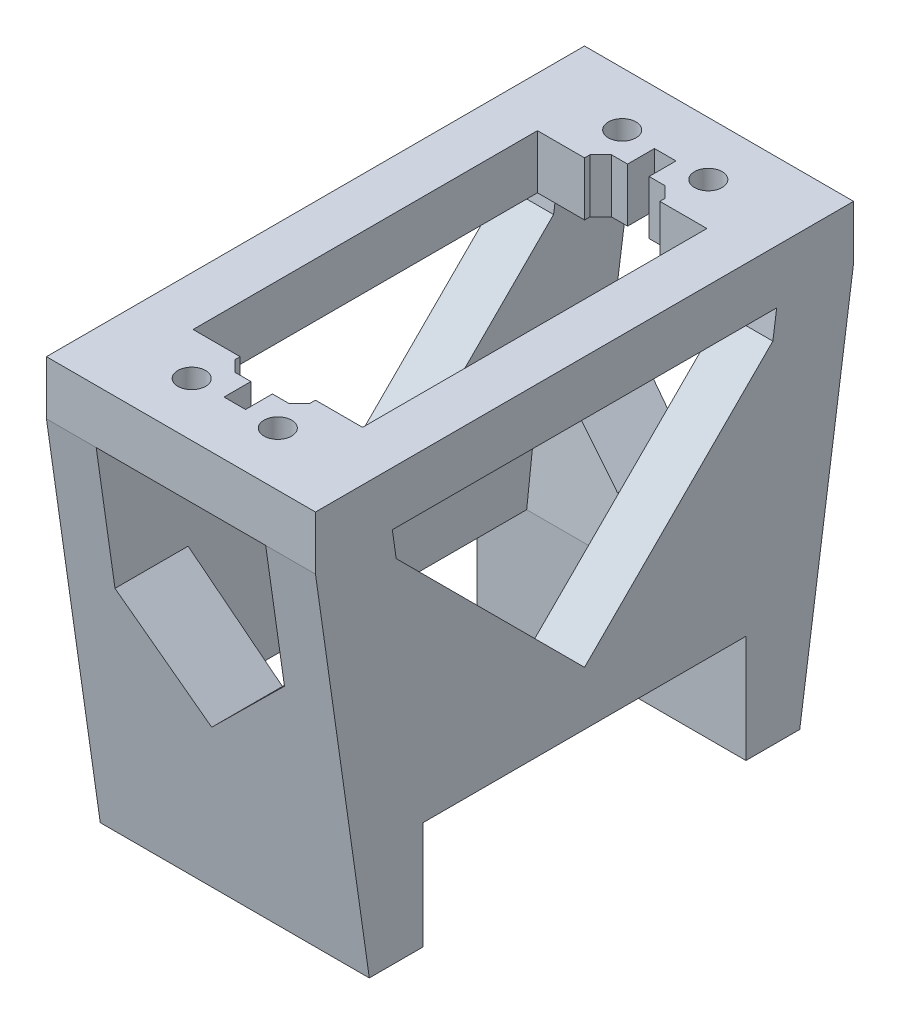
from build123d import *
from build123d.topology import SkipClean

# Parameters (mm, degrees)
SKETCH2_W           = 31.75
SKETCH2_H           = 6.35
BOSS_EXTRUDE2_DEPTH = 31.75
SKETCH3_W           = 19.999999878
SKETCH3_H           = 40.64
CUT_EXTRUDE1_DEPTH  = 37.061067996
SKETCH4_R           = 1.63195
CUT_EXTRUDE2_DEPTH  = 37.061067996
SKETCH7_W           = 3.175
SKETCH7_H           = 1.905
SKETCH7_W_2         = 2.54
SKETCH7_H_2         = 3.175
CUT_EXTRUDE4_DEPTH  = 37.061067996
CHAMFER1_SIZE       = 1.27
CUT_EXTRUDE3_DEPTH  = 2.38125
BOSS_EXTRUDE5_DEPTH = 31.75
SKETCH12_W          = 19.999999878
SKETCH12_H          = 25.4
CUT_EXTRUDE5_DEPTH  = 81.946934778
BOSS_EXTRUDE6_DEPTH = 9.071430469
BOSS_EXTRUDE7_DEPTH = 9.071428449
BOSS_EXTRUDE8_DEPTH = 31.75
SKETCH16_W          = 19.999999878
SKETCH16_H          = 45.357142858
SKETCH18_W          = 19.999999878
SKETCH18_H          = 38.1


with BuildPart() as part:
    # Sketch2 → Boss-Extrude2 (new, symmetric)
    with BuildSketch(Plane.XY):
        Rectangle(SKETCH2_W, SKETCH2_H)
    extrude(amount=BOSS_EXTRUDE2_DEPTH, both=True)

    # Sketch3 → Cut-Extrude1 (cut, through all)
    with BuildSketch(Plane(origin=(0, 3.175, 0), x_dir=(1, 0, 0), z_dir=(0, 1, 0))):
        Rectangle(SKETCH3_W, SKETCH3_H)
    extrude(amount=-CUT_EXTRUDE1_DEPTH, mode=Mode.SUBTRACT)

    # Sketch4 → Cut-Extrude2 (cut, through all)
    with BuildSketch(Plane(origin=(0, 3.175, 0), x_dir=(1, 0, 0), z_dir=(0, 1, 0))):
        with Locations(Location((-5.08, 25.4, 0), (0, 0, 270))):
            Circle(SKETCH4_R)
        with Locations(Location((5.08, 25.4, 0), (0, 0, 270))):
            Circle(SKETCH4_R)
        with Locations(Location((-5.08, -25.4, 0), (0, 0, 270))):
            Circle(SKETCH4_R)
        with Locations(Location((5.08, -25.4, 0), (0, 0, 270))):
            Circle(SKETCH4_R)
    extrude(amount=-CUT_EXTRUDE2_DEPTH, mode=Mode.SUBTRACT)

    # Sketch7 → Cut-Extrude4 (cut, through all)
    with BuildSketch(Plane(origin=(0, 3.175, 0), x_dir=(1, 0, 0), z_dir=(0, 1, 0))):
        with Locations((-2.8575, 21.2725)):
            Rectangle(SKETCH7_W, SKETCH7_H)
        with Locations((2.8575, 21.2725)):
            Rectangle(SKETCH7_W, SKETCH7_H)
        with Locations((2.8575, -21.2725)):
            Rectangle(SKETCH7_W, SKETCH7_H)
        with Locations((-2.8575, -21.2725)):
            Rectangle(SKETCH7_W, SKETCH7_H)
        with Locations((0, 21.2725)):
            Rectangle(SKETCH7_W_2, SKETCH7_H)
        with Locations((0, 23.8125)):
            Rectangle(SKETCH7_W_2, SKETCH7_H_2)
        with Locations((0, -21.2725)):
            Rectangle(SKETCH7_W_2, SKETCH7_H)
        with Locations((0, -23.8125)):
            Rectangle(SKETCH7_W_2, SKETCH7_H_2)
    extrude(amount=-CUT_EXTRUDE4_DEPTH, mode=Mode.SUBTRACT)

    # Chamfer1
    chamfer1_edges = [part.edges().sort_by_distance(p)[0] for p in [
        (-4.445, 0, -22.225),
        (4.445, 0, -22.225),
        (4.445, 0, 22.225),
        (-4.445, 0, 22.225),
    ]]
    chamfer(chamfer1_edges, length=CHAMFER1_SIZE)

    # Sketch6 → Cut-Extrude3 (cut)
    with BuildSketch(Plane.XZ.offset(3.175)):
        Polygon((-1.905, 27.233087105), (-5.08, 29.066174209), (-8.255, 27.233087105), (-8.255, 23.566912895), (-5.08, 21.733825791), (-1.905, 23.566912895), align=None)
        Polygon((8.255, 27.233087105), (5.08, 29.066174209), (1.905, 27.233087105), (1.905, 23.566912895), (5.08, 21.733825791), (8.255, 23.566912895), align=None)
        Polygon((8.255, -23.566912895), (5.08, -21.733825791), (1.905, -23.566912895), (1.905, -27.233087105), (5.08, -29.066174209), (8.255, -27.233087105), align=None)
        Polygon((-1.905, -23.566912895), (-5.08, -21.733825791), (-8.255, -23.566912895), (-8.255, -27.233087105), (-5.08, -29.066174209), (-1.905, -27.233087105), align=None)
    extrude(amount=-CUT_EXTRUDE3_DEPTH, mode=Mode.SUBTRACT)

    # Sketch10 → Boss-Extrude5 (add, through all)
    with BuildSketch(Plane(origin=(15.875, 0, 0), x_dir=(0, 0, -1), z_dir=(1, 0, 0))):
        Polygon((25.4, -47.625), (19.05, -47.625), (19.05, -34.925), (-19.05, -34.925), (-19.05, -47.625), (-25.4, -47.625), (-31.75, -3.175), (-22.678571429, -3.175), (-19.05, -28.575), (19.05, -28.575), (22.678571429, -3.175), (31.75, -3.175), align=None)
    extrude(amount=-BOSS_EXTRUDE5_DEPTH)

    # Sketch12 → Cut-Extrude5 (cut, through all)
    with BuildSketch(Plane.XY.offset(31.75)):
        with Locations((0, -15.875)):
            Rectangle(SKETCH12_W, SKETCH12_H)
    extrude(amount=-CUT_EXTRUDE5_DEPTH, mode=Mode.SUBTRACT)

    # Sketch13 → Boss-Extrude6 (add, along a direction that is not the sketch's normal)
    with BuildSketch(Plane(origin=(0, -4.5085, -31.5595), x_dir=(-1, 0, 0), z_dir=(0, -0.14142135623730953, -0.9899494936611667))):
        Polygon((-9.999999939, -24.310836213), (0, -24.310836213), (-9.999999939, -14.310836274), align=None)
        Polygon((9.999999939, -14.310836274), (0, -24.310836213), (9.999999939, -24.310836213), align=None)
    extrude(amount=-BOSS_EXTRUDE6_DEPTH, dir=(0, 0, -1))

    # Sketch14 → Boss-Extrude7 (add, along a direction that is not the sketch's normal)
    with SkipClean():  # the faces are left unmerged after this step: merging them gives an invalid solid
        with BuildSketch(Plane(origin=(0, -4.5085, 31.5595), x_dir=(1, 0, 0), z_dir=(0, -0.14142135623730945, 0.9899494936611667))):
            Polygon((-9.999999939, -24.310836213), (0, -24.310836213), (-9.999999939, -14.310836274), align=None)
            Polygon((9.999999939, -14.310836274), (0, -24.310836213), (9.999999939, -24.310836213), align=None)
        extrude(amount=-BOSS_EXTRUDE7_DEPTH, dir=(0, 0, 1))

    # Sketch15 → Boss-Extrude8 (add)
    with BuildSketch(Plane(origin=(15.875, 0, 0), x_dir=(0, 0, -1), z_dir=(1, 0, 0))):
        Polygon((22.225, -6.35), (0, -28.575), (19.05, -28.575), align=None)
        Polygon((-19.05, -28.575), (0, -28.575), (-22.225, -6.35), align=None)
    extrude(amount=-BOSS_EXTRUDE8_DEPTH)

    # Sketch16 → Cut-Loft1 section 0
    with BuildSketch(Plane.XZ.offset(3.175)):
        Rectangle(SKETCH16_W, SKETCH16_H)
    # Sketch18 → Cut-Loft1 section 1
    with BuildSketch(Plane.XZ.offset(34.925)):
        Rectangle(SKETCH18_W, SKETCH18_H)
    loft(mode=Mode.SUBTRACT)


solid = part.part
